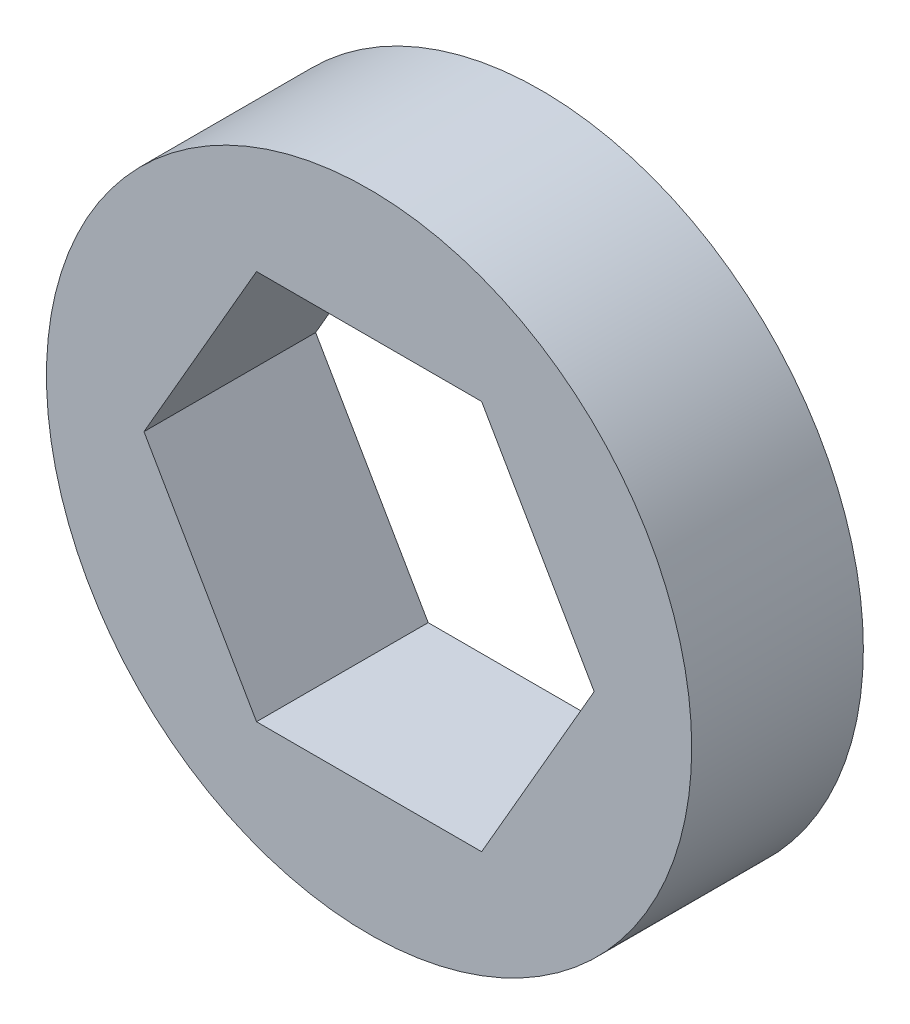
from build123d import *

# Parameters (mm, degrees)
SKETCH1_R           = 10.5029
BOSS_EXTRUDE1_DEPTH = 5.588


with BuildPart() as part:
    # Sketch1 → Boss-Extrude1 (new body)
    with BuildSketch(Plane.XY):
        Circle(SKETCH1_R)
        Polygon((-7.3279, 0), (-3.66395, -6.346147556), (3.66395, -6.346147556), (7.3279, 0), (3.66395, 6.346147556), (-3.66395, 6.346147556), align=None, mode=Mode.SUBTRACT)
    extrude(amount=BOSS_EXTRUDE1_DEPTH)


solid = part.part
